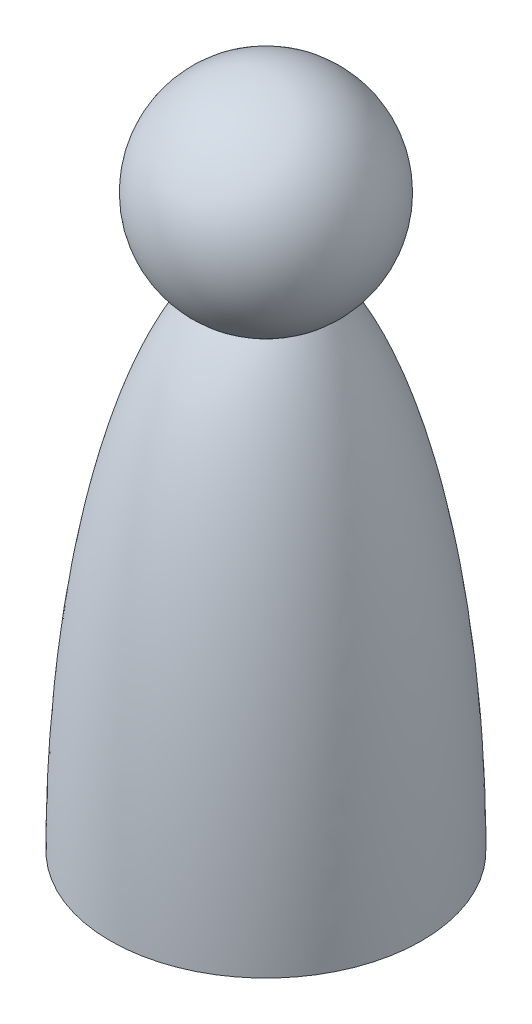
from build123d import *


with BuildPart() as part:
    # Sketch1 → Revolve1 (revolve)
    with BuildSketch(Plane.XY):
        with BuildLine():
            Line((-19.05, 0), (-12.7, 0))
            Line((-12.7, 0), (-12.7, -3.683))
            Line((-12.7, -3.683), (0, -3.683))
            Line((0, -3.683), (0, 69.85))
            Line((0, 69.85), (0, 82.55))
            ThreePointArc((0, 82.55), (-12.179839934, 73.447429524), (-6.900175713, 59.188031367))
            add(Edge.make_bspline(
                [(-6.900175713, 59.188031367), (-19.05, 43.449879108), (-19.05, 0)],
                knots=[3.512234693, 3.512234693, 3.512234693, 4.71238898, 4.71238898, 4.71238898], degree=2, weights=[1, 0.825292054, 1]))
        make_face()
    revolve(axis=Axis((0, 0, 0), (0, -1, 0)))


solid = part.part
